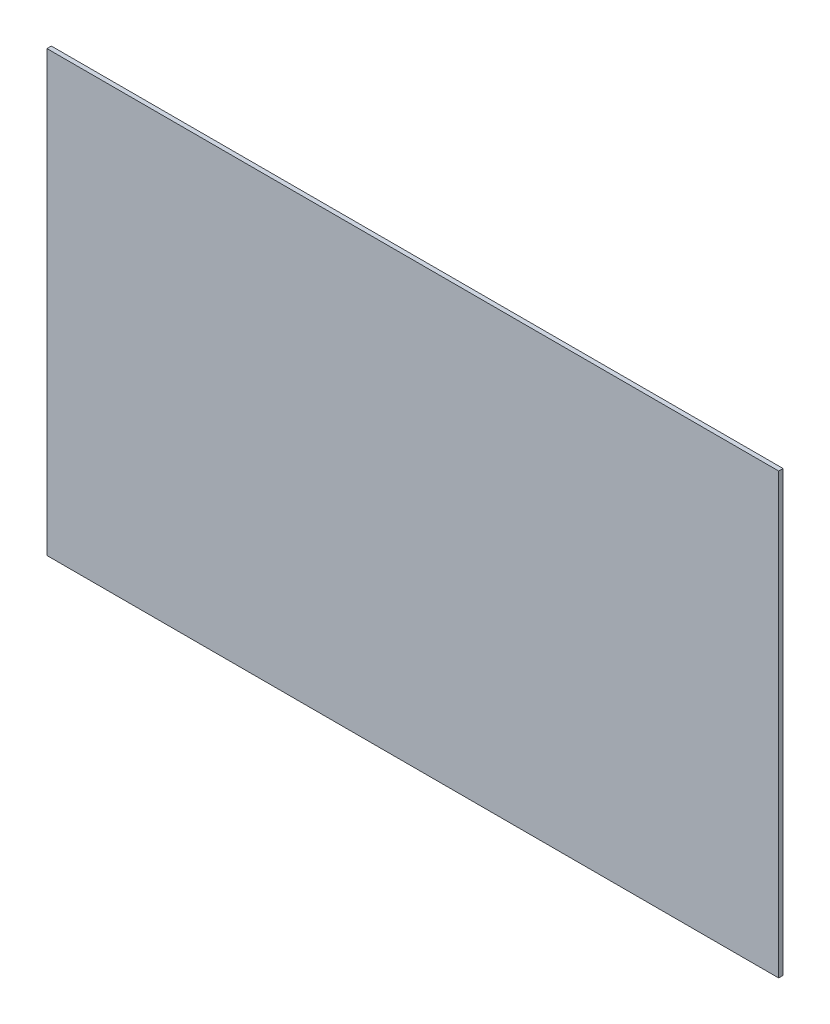
from build123d import *

# Parameters (mm, degrees)
IZIM1_W                     = 500
IZIM1_H                     = 300
Y_KSEKLIK_EKSTR_ZYON1_DEPTH = 3


with BuildPart() as part:
    # Çizim1 → Yükseklik-Ekstrüzyon1 (new body)
    with BuildSketch(Plane.XY):
        with Locations((250, -150)):
            Rectangle(IZIM1_W, IZIM1_H)
    extrude(amount=Y_KSEKLIK_EKSTR_ZYON1_DEPTH)


solid = part.part
